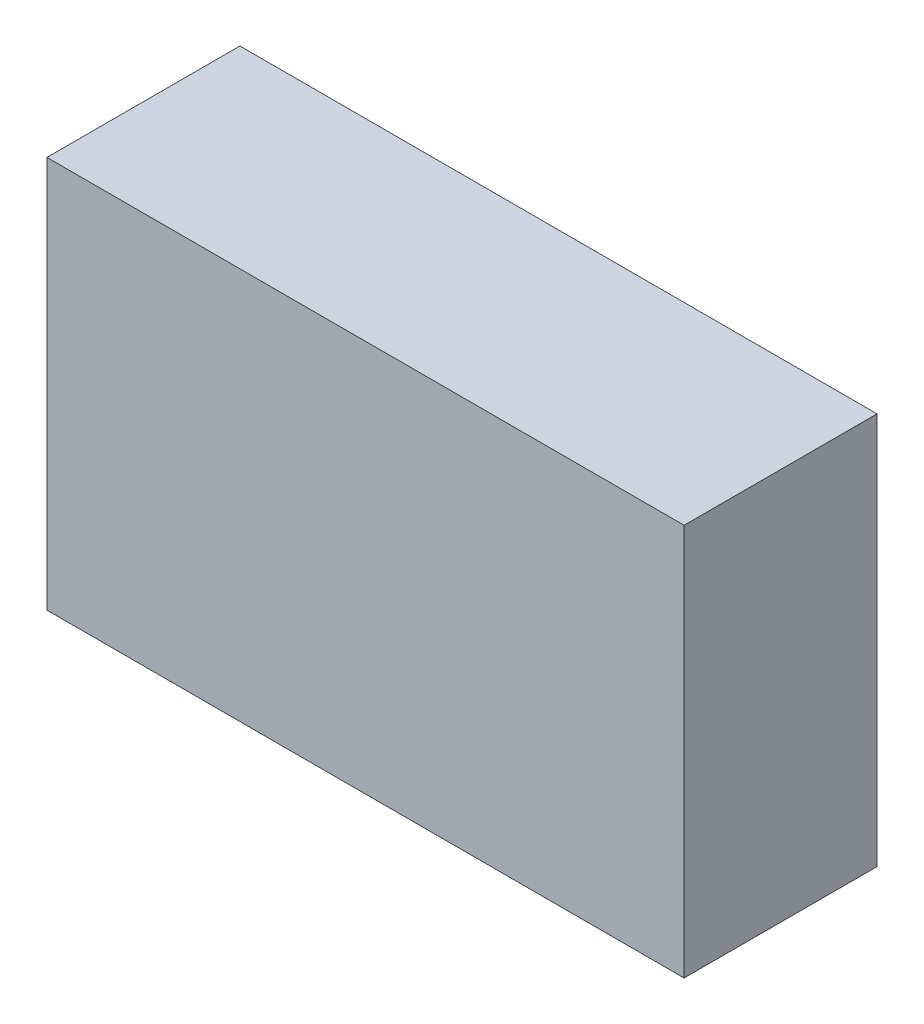
from build123d import *

# Parameters (mm, degrees)
SKETCH1_W               = 3.302
SKETCH1_H               = 2.032
COMPONENT_OUTLINE_DEPTH = 1


with BuildPart() as part:
    # Sketch1 → Component_Outline (new body)
    with BuildSketch(Plane.XY):
        with Locations((-0.127, 0)):
            Rectangle(SKETCH1_W, SKETCH1_H)
    extrude(amount=COMPONENT_OUTLINE_DEPTH)


solid = part.part
